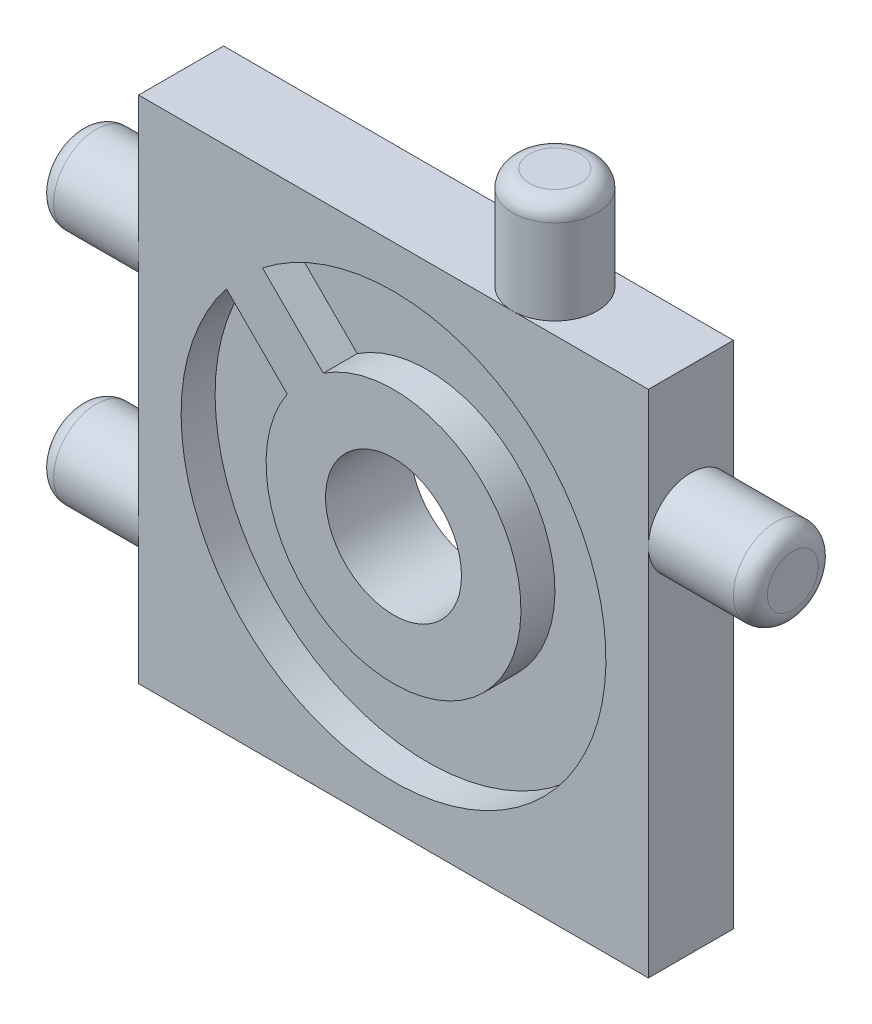
from build123d import *

# Parameters (mm, degrees)
ESQUISSE2_W              = 30
ESQUISSE2_H              = 30
BOSS_EXTRU_1_DEPTH       = 5
ESQUISSE16_R             = 2.5
BOSS_EXTRU_7_DEPTH       = 6
CONG_3_R                 = 1
ESQUISSE18_R             = 2.5
BOSS_EXTRU_9_DEPTH       = 6
CONG_5_R                 = 1
ESQUISSE8_R              = 12.5
ENL_V_MAT_EXTRU_1_DEPTH  = 2
ESQUISSE19_R             = 7.5
BOSS_EXTRU_10_DEPTH      = 2
ESQUISSE33_R             = 4
ENL_V_MAT_EXTRU_3_DEPTH  = 6
ESQUISSE35_R             = 2.5
BOSS_EXTRU_26_DEPTH      = 6
CONG_6_R                 = 1
BOSS_EXTRU_27_DEPTH      = 2
BOSS_EXTRU_27_DEPTH_BACK = 5.5


with BuildPart() as part:
    # Esquisse2 → Boss.-Extru.1 (new body)
    with BuildSketch(Plane.XY):
        Rectangle(ESQUISSE2_W, ESQUISSE2_H)
    extrude(amount=BOSS_EXTRU_1_DEPTH)

    # Esquisse16 → Boss.-Extru.7 (add)
    with BuildSketch(Plane.ZY.offset(15)):
        with Locations((2.5, 7)):
            Circle(ESQUISSE16_R)
        with Locations((2.5, -7)):
            Circle(ESQUISSE16_R)
    extrude(amount=BOSS_EXTRU_7_DEPTH)

    # Congé3
    cong_3_edges = [part.edges().sort_by_distance(p)[0] for p in [
        (-21, 7, 0),
        (-21, -7, 0),
    ]]
    fillet(cong_3_edges, radius=CONG_3_R)

    # Esquisse18 → Boss.-Extru.9 (add)
    with BuildSketch(Plane(origin=(15, 0, 0), x_dir=(0, 0, -1), z_dir=(1, 0, 0))):
        with Locations((-2.5, 7)):
            Circle(ESQUISSE18_R)
    extrude(amount=BOSS_EXTRU_9_DEPTH)

    # Congé5
    cong_5_edges = [part.edges().sort_by_distance(p)[0] for p in [
        (21, 7, 5),
    ]]
    fillet(cong_5_edges, radius=CONG_5_R)

    # Esquisse8 → Enlèv. mat.-Extru.1 (cut)
    with BuildSketch(Plane.XY.offset(5)):
        Circle(ESQUISSE8_R)
    extrude(amount=-ENL_V_MAT_EXTRU_1_DEPTH, mode=Mode.SUBTRACT)

    # Esquisse19 → Boss.-Extru.10 (add)
    with BuildSketch(Plane.XY.offset(3)):
        Circle(ESQUISSE19_R)
    extrude(amount=BOSS_EXTRU_10_DEPTH)

    # Esquisse33 → Enlèv. mat.-Extru.3 (cut, through all)
    with BuildSketch(Plane.XY.offset(5)):
        Circle(ESQUISSE33_R)
    extrude(amount=-ENL_V_MAT_EXTRU_3_DEPTH, mode=Mode.SUBTRACT)

    # Esquisse35 → Boss.-Extru.26 (add)
    with BuildSketch(Plane(origin=(0, 15, 0), x_dir=(1, 0, 0), z_dir=(0, 1, 0))):
        with Locations((7, -2.5)):
            Circle(ESQUISSE35_R)
    extrude(amount=BOSS_EXTRU_26_DEPTH)

    # Congé6
    cong_6_edges = [part.edges().sort_by_distance(p)[0] for p in [
        (4.5, 21, 2.5),
    ]]
    fillet(cong_6_edges, radius=CONG_6_R)

    # Esquisse31 → Boss.-Extru.27 (add, two sides)
    with BuildSketch(Plane.XY.offset(3)) as boss_extru_27_sk:
        Polygon((-9.899494937, 7.778174593), (-7.778174593, 9.899494937), (-3.545672625, 5.666992969), (-5.666992969, 3.545672625), align=None)
    extrude(amount=BOSS_EXTRU_27_DEPTH)
    extrude(boss_extru_27_sk.sketch, amount=-BOSS_EXTRU_27_DEPTH_BACK)


solid = part.part
